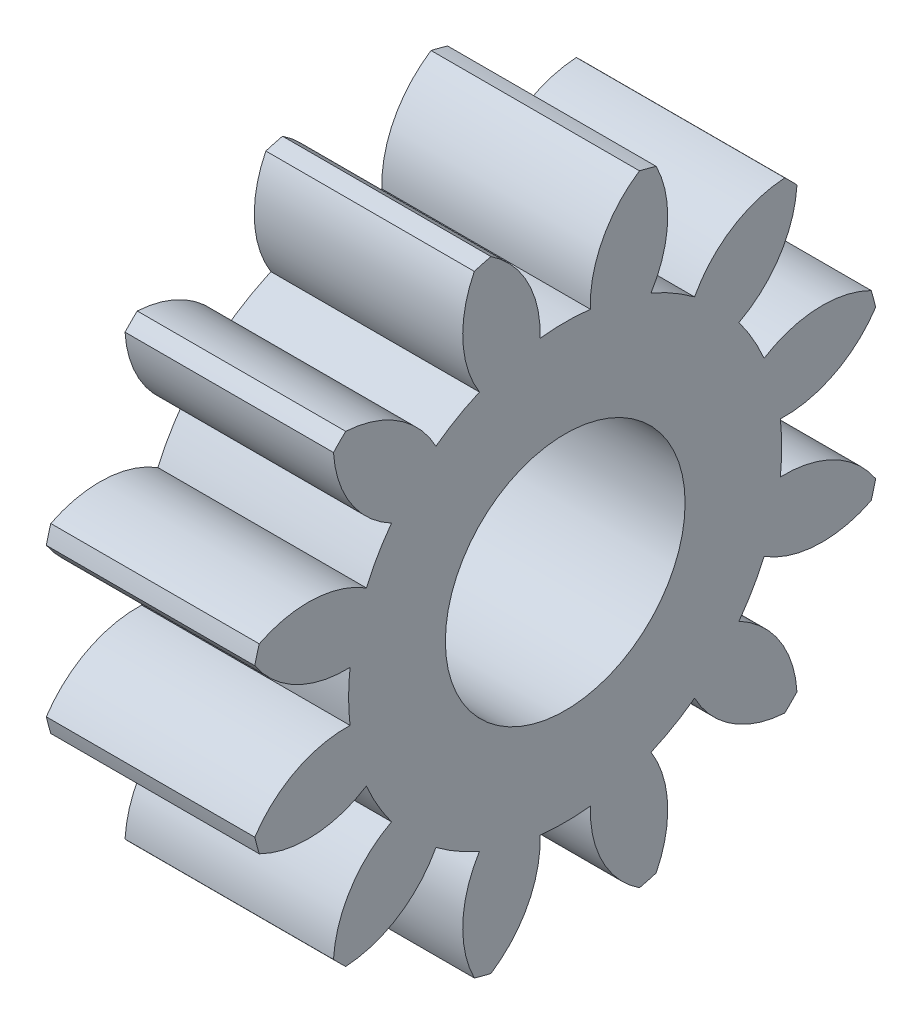
from build123d import *
from build123d.topology import SkipClean

# Parameters (mm, degrees)
BASPROSKE_W             = 8
BASPROSKE_H             = 12.25
TOOTHCUT_DEPTH          = 20.082059637
TEETHCUTS_COUNT         = 12
TEETHCUTS_ANGLE         = 330
HUBNEAONESKE_R          = 8.3115
HUBNEARONE_DEPTH        = 8.0000508
BORSKE_R                = 4.5
BORE_DEPTH              = 16.0000508
ESQUISSE1_R             = 8.3115
ENL_V_MAT_EXTRU_1_DEPTH = 8
ESQUISSE2_R             = 4.5
ESQUISSE2_R_2           = 4.275
BOSS_EXTRU_1_DEPTH      = 8
ESQUISSE3_R             = 4.6
ENL_V_MAT_EXTRU_2_DEPTH = 10


with BuildPart() as part:
    # BasProSke → Base-Revolve (revolve)
    with BuildSketch(Plane(origin=(0, 0, 0), x_dir=(1, 0, 0), z_dir=(0, 1, 0)), mode=Mode.PRIVATE) as base_revolve_sk:
        with Locations((4, 6.125)):
            Rectangle(BASPROSKE_W, BASPROSKE_H)
    revolve(base_revolve_sk.sketch.rotate(Axis((-10, 0, 0), (1, 0, 0)), 180), axis=Axis((-10, 0, 0), (1, 0, 0)))

    # TooCutSke → ToothCut (cut, through all)
    with BuildSketch(Plane(origin=(0, 0, 0), x_dir=(0, 0, -1), z_dir=(1, 0, 0))):
        with BuildLine():
            ThreePointArc((0.965128363, 8.255274647), (0, 8.3115), (-0.965128363, 8.255274647))
            ThreePointArc((-0.965128363, 8.255274647), (-1.43628674, 10.346733197), (-2.878284339, 11.933185846))
            ThreePointArc((-2.878284339, 11.933185846), (0, 12.2754), (2.878284339, 11.933185846))
            ThreePointArc((2.878284339, 11.933185846), (1.43628674, 10.346733197), (0.965128363, 8.255274647))
        make_face()
    toothcut = extrude(amount=TOOTHCUT_DEPTH, mode=Mode.SUBTRACT)

    # TeethCuts: ToothCut ×12 about axis
    teethcuts_axis = Axis((-10, 0, 0), (1, 0, 0))
    for i in range(1, TEETHCUTS_COUNT):
        add(toothcut.rotate(teethcuts_axis, i * TEETHCUTS_ANGLE / (TEETHCUTS_COUNT - 1)), mode=Mode.SUBTRACT)

    # HubNeaOneSke → HubNearOne (add)
    with SkipClean():  # the faces are left unmerged after this step: merging them gives an invalid solid
        with BuildSketch(Plane.ZY):
            Circle(HUBNEAONESKE_R)
        extrude(amount=HUBNEARONE_DEPTH)

    # BorSke → Bore (cut, symmetric)
    with SkipClean():  # the faces are left unmerged after this step: merging them gives an invalid solid
        with BuildSketch(Plane(origin=(0, 0, 0), x_dir=(0, 0, -1), z_dir=(1, 0, 0))):
            with Locations(Location((0, 0, 0), (0, 0, 180))):
                Circle(BORSKE_R)
        extrude(amount=BORE_DEPTH, both=True, mode=Mode.SUBTRACT)

    # Esquisse1 → Enlèv. mat.-Extru.1 (cut)
    with SkipClean():  # the faces are left unmerged after this step: merging them gives an invalid solid
        with BuildSketch(Plane.ZY.offset(8.0000508)):
            Circle(ESQUISSE1_R)
        extrude(amount=-ENL_V_MAT_EXTRU_1_DEPTH, mode=Mode.SUBTRACT)

    # Esquisse2 → Boss.-Extru.1 (add)
    with SkipClean():  # the faces are left unmerged after this step: merging them gives an invalid solid
        with BuildSketch(Plane(origin=(8, 0, 0), x_dir=(0, 0, -1), z_dir=(1, 0, 0))):
            with Locations(Location((0, 0, 0), (0, 0, 180))):
                Circle(ESQUISSE2_R)
            Circle(ESQUISSE2_R_2, mode=Mode.SUBTRACT)
        extrude(amount=-BOSS_EXTRU_1_DEPTH)

    # Esquisse3 → Enlèv. mat.-Extru.2 (cut)
    with SkipClean():  # the faces are left unmerged after this step: merging them gives an invalid solid
        with BuildSketch(Plane.ZY.offset(5.08e-05)):
            Circle(ESQUISSE3_R)
        extrude(amount=-ENL_V_MAT_EXTRU_2_DEPTH, mode=Mode.SUBTRACT)


solid = part.part
